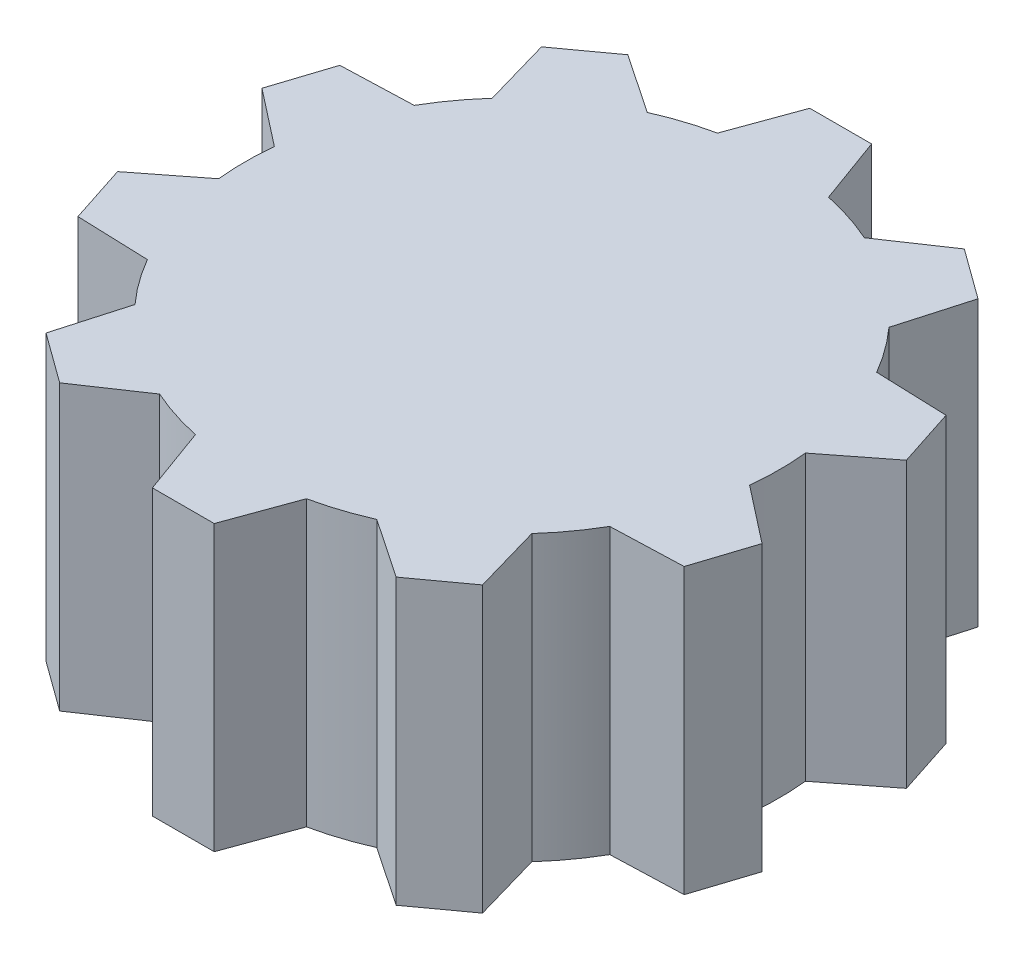
from build123d import *

# Parameters (mm, degrees)
CROQUIS1_R              = 3.75
SALIENTE_EXTRUIR1_DEPTH = 11.5
CROQUIS1_4_R            = 1.1
CORTAR_EXTRUIR1_DEPTH   = 1.7
CORTAR_EXTRUIR2_START   = 1.7
CORTAR_EXTRUIR2_DEPTH   = 1.2
CUT_EXTRUDE1_START      = 1.7
CROQUIS1_7_R            = 1.1
CUT_EXTRUDE1_DEPTH      = 6.5
BOSS_EXTRUDE1_START     = 11.5
BOSS_EXTRUDE1_DEPTH     = 5.6


with BuildPart() as part:
    # Croquis1 → Saliente-Extruir1 (new body)
    with BuildSketch(Plane(origin=(0, 0, 0), x_dir=(1, 0, 0), z_dir=(0, 1, 0))):
        with BuildLine():
            Line((1.248257156, 13.300370373), (-1.251742735, 13.299629349))
            Line((-1.251742735, 13.299629349), (-2.247599184, 10.563536241))
            ThreePointArc((-2.247599184, 10.563536241), (-3.339078028, 10.270859649), (-4.394000333, 9.865736722))
            Line((-4.394000333, 9.865736722), (-6.807900303, 11.493932811))
            Line((-6.807900303, 11.493932811), (-8.830007137, 10.023870243))
            Line((-8.830007137, 10.023870243), (-8.027436751, 7.224974686))
            ThreePointArc((-8.027436751, 7.224974686), (-8.7384307, 6.346639181), (-9.353755491, 5.398820076))
            Line((-9.353755491, 5.398820076), (-12.263671238, 5.297203579))
            Line((-12.263671238, 5.297203579), (-13.035508935, 2.919333403))
            Line((-13.035508935, 2.919333403), (-10.741066321, 1.126718369))
            ThreePointArc((-10.741066321, 1.126718369), (-10.799999853, -0.001781739), (-10.740693974, -1.13026234))
            Line((-10.740693974, -1.13026234), (-13.035136587, -2.922877375))
            Line((-13.035136587, -2.922877375), (-12.261889379, -5.300289572))
            Line((-12.261889379, -5.300289572), (-9.351973632, -5.401906069))
            ThreePointArc((-9.351973632, -5.401906069), (-8.73633614, -6.349522096), (-8.025052421, -7.227622959))
            Line((-8.025052421, -7.227622959), (-8.827622808, -10.026518516))
            Line((-8.827622808, -10.026518516), (-6.804644848, -11.495382082))
            Line((-6.804644848, -11.495382082), (-4.390744878, -9.867185993))
            ThreePointArc((-4.390744878, -9.867185993), (-3.335688959, -10.271960824), (-2.244113605, -10.564277265))
            Line((-2.244113605, -10.564277265), (-1.248257156, -13.300370373))
            Line((-1.248257156, -13.300370373), (1.251742735, -13.299629349))
            Line((1.251742735, -13.299629349), (2.247599184, -10.563536241))
            ThreePointArc((2.247599184, -10.563536241), (3.339078028, -10.270859649), (4.394000333, -9.865736722))
            Line((4.394000333, -9.865736722), (6.807900303, -11.493932811))
            Line((6.807900303, -11.493932811), (8.830007137, -10.023870243))
            Line((8.830007137, -10.023870243), (8.027436751, -7.224974686))
            ThreePointArc((8.027436751, -7.224974686), (8.7384307, -6.346639181), (9.353755491, -5.398820076))
            Line((9.353755491, -5.398820076), (12.263671238, -5.297203579))
            Line((12.263671238, -5.297203579), (13.035508935, -2.919333403))
            Line((13.035508935, -2.919333403), (10.741066321, -1.126718369))
            ThreePointArc((10.741066321, -1.126718369), (10.799999853, 0.001781739), (10.740693974, 1.13026234))
            Line((10.740693974, 1.13026234), (13.035136587, 2.922877375))
            Line((13.035136587, 2.922877375), (12.261889379, 5.300289572))
            Line((12.261889379, 5.300289572), (9.351973632, 5.401906069))
            ThreePointArc((9.351973632, 5.401906069), (8.73633614, 6.349522096), (8.025052421, 7.227622959))
            Line((8.025052421, 7.227622959), (8.827622808, 10.026518516))
            Line((8.827622808, 10.026518516), (6.804644848, 11.495382082))
            Line((6.804644848, 11.495382082), (4.390744878, 9.867185993))
            ThreePointArc((4.390744878, 9.867185993), (3.335688959, 10.271960824), (2.244113605, 10.564277265))
            Line((2.244113605, 10.564277265), (1.248257156, 13.300370373))
        make_face()
        with Locations(Location((0, 0, 0), (0, 0, 270))):
            Circle(CROQUIS1_R, mode=Mode.SUBTRACT)
    extrude(amount=SALIENTE_EXTRUIR1_DEPTH)

    # Croquis1_4 → Cortar-Extruir1 (cut)
    with BuildSketch(Plane(origin=(0, 0, 0), x_dir=(1, 0, 0), z_dir=(0, 1, 0))):
        with BuildLine():
            ThreePointArc((3.727502093, -0.41015625), (0, -3.75), (-3.727502093, -0.41015625))
            Line((-3.727502093, -0.41015625), (-3.249966737, -4.75))
            Line((-3.249966737, -4.75), (3.249966737, -4.75))
            Line((3.249966737, -4.75), (3.727502093, -0.41015625))
        make_face()
        with BuildLine():
            Line((3.249966737, -4.75), (-3.249966737, -4.75))
            Line((-3.249966737, -4.75), (-2.737205389, -9.409977746))
            ThreePointArc((-2.737205389, -9.409977746), (0, -9.7999987), (2.737205389, -9.409977746))
            Line((2.737205389, -9.409977746), (3.249966737, -4.75))
        make_face()
        with Locations((0, -7)):
            Circle(CROQUIS1_4_R, mode=Mode.SUBTRACT)
        with BuildLine():
            Line((3.248223947, 4.75), (-3.251709526, 4.75))
            Line((-3.251709526, 4.75), (-3.727664518, 0.408677426))
            ThreePointArc((-3.727664518, 0.408677426), (-0.001487905, 3.749999705), (3.727339039, 0.411635384))
            Line((3.727339039, 0.411635384), (3.248223947, 4.75))
        make_face()
        with BuildLine():
            Line((-2.740938342, 9.408891089), (-3.251709526, 4.75))
            Line((-3.251709526, 4.75), (3.248223947, 4.75))
            Line((3.248223947, 4.75), (2.733471058, 9.411063197))
            ThreePointArc((2.733471058, 9.411063197), (-0.003888392, 9.799997928), (-2.740938342, 9.408891089))
        make_face()
        with Locations((0, 7)):
            Circle(CROQUIS1_4_R, mode=Mode.SUBTRACT)
        with Locations((0, 7)):
            Circle(CROQUIS1_4_R)
        with Locations((0, -7)):
            Circle(CROQUIS1_4_R)
    extrude(amount=CORTAR_EXTRUIR1_DEPTH, mode=Mode.SUBTRACT)

    # Croquis1_5 → Cortar-Extruir2 (cut)
    with BuildSketch(Plane(origin=(0, 0, 0), x_dir=(1, 0, 0), z_dir=(0, 1, 0)).offset(CORTAR_EXTRUIR2_START)):
        with BuildLine():
            Line((3.248223947, 4.75), (-3.251709526, 4.75))
            Line((-3.251709526, 4.75), (-3.727664518, 0.408677426))
            ThreePointArc((-3.727664518, 0.408677426), (-0.001487905, 3.749999705), (3.727339039, 0.411635384))
            Line((3.727339039, 0.411635384), (3.248223947, 4.75))
        make_face()
        with BuildLine():
            ThreePointArc((3.727502093, -0.41015625), (0, -3.75), (-3.727502093, -0.41015625))
            Line((-3.727502093, -0.41015625), (-3.249966737, -4.75))
            Line((-3.249966737, -4.75), (3.249966737, -4.75))
            Line((3.249966737, -4.75), (3.727502093, -0.41015625))
        make_face()
    extrude(amount=CORTAR_EXTRUIR2_DEPTH, mode=Mode.SUBTRACT)

    # Croquis1_7 → Cut-Extrude1 (cut)
    with BuildSketch(Plane(origin=(0, 0, 0), x_dir=(1, 0, 0), z_dir=(0, 1, 0)).offset(CUT_EXTRUDE1_START)):
        with Locations(Location((0, -7, 0), (0, 0, 90))):
            Circle(CROQUIS1_7_R)
        with Locations(Location((0, 7, 0), (0, 0, 90))):
            Circle(CROQUIS1_7_R)
    extrude(amount=CUT_EXTRUDE1_DEPTH, mode=Mode.SUBTRACT)

    # Croquis1_10 → Boss-Extrude1 (add)
    with BuildSketch(Plane(origin=(0, 0, 0), x_dir=(1, 0, 0), z_dir=(0, 1, 0)).offset(BOSS_EXTRUDE1_START)):
        with BuildLine():
            ThreePointArc((0, 1.6), (-1.6, 0), (0, -1.6))
            Line((0, -1.6), (0, 1.6))
        make_face()
        with BuildLine():
            Line((0, 1.6), (0, -1.6))
            ThreePointArc((0, -1.6), (1.13137085, -1.13137085), (1.6, 0))
            ThreePointArc((1.6, 0), (1.13137085, 1.13137085), (0, 1.6))
        make_face()
        with BuildLine():
            ThreePointArc((0, 2.6), (-2.6, 0), (0, -2.6))
            Line((0, -2.6), (0, -1.6))
            ThreePointArc((0, -1.6), (-1.6, 0), (0, 1.6))
            Line((0, 1.6), (0, 2.6))
        make_face()
        with BuildLine():
            Line((0, -1.6), (0, -2.6))
            ThreePointArc((0, -2.6), (1.838477631, -1.838477631), (2.6, 0))
            ThreePointArc((2.6, 0), (1.838477631, 1.838477631), (0, 2.6))
            Line((0, 2.6), (0, 1.6))
            ThreePointArc((0, 1.6), (1.13137085, 1.13137085), (1.6, 0))
            ThreePointArc((1.6, 0), (1.13137085, -1.13137085), (0, -1.6))
        make_face()
        with BuildLine():
            ThreePointArc((-3.727502093, -0.41015625), (-2.502440215, -2.792900458), (0, -3.75))
            Line((0, -3.75), (0, -2.6))
            ThreePointArc((0, -2.6), (-2.6, 0), (0, 2.6))
            Line((0, 2.6), (0, 3.75))
            ThreePointArc((0, 3.75), (-2.502994172, 2.792404013), (-3.727664518, 0.408677426))
            ThreePointArc((-3.727664518, 0.408677426), (-3.749999926, -0.000743858), (-3.727502093, -0.41015625))
        make_face()
        with BuildLine():
            Line((0, -2.6), (0, -3.75))
            ThreePointArc((0, -3.75), (2.502440215, -2.792900458), (3.727502093, -0.41015625))
            ThreePointArc((3.727502093, -0.41015625), (3.744371299, -0.205386407), (3.75, 0))
            ThreePointArc((3.75, 0), (3.744330474, 0.206129334), (3.727339039, 0.411635384))
            ThreePointArc((3.727339039, 0.411635384), (2.50188602, 2.793396919), (0, 3.75))
            Line((0, 3.75), (0, 2.6))
            ThreePointArc((0, 2.6), (1.838477631, 1.838477631), (2.6, 0))
            ThreePointArc((2.6, 0), (1.838477631, -1.838477631), (0, -2.6))
        make_face()
    extrude(amount=-BOSS_EXTRUDE1_DEPTH)


solid = part.part
